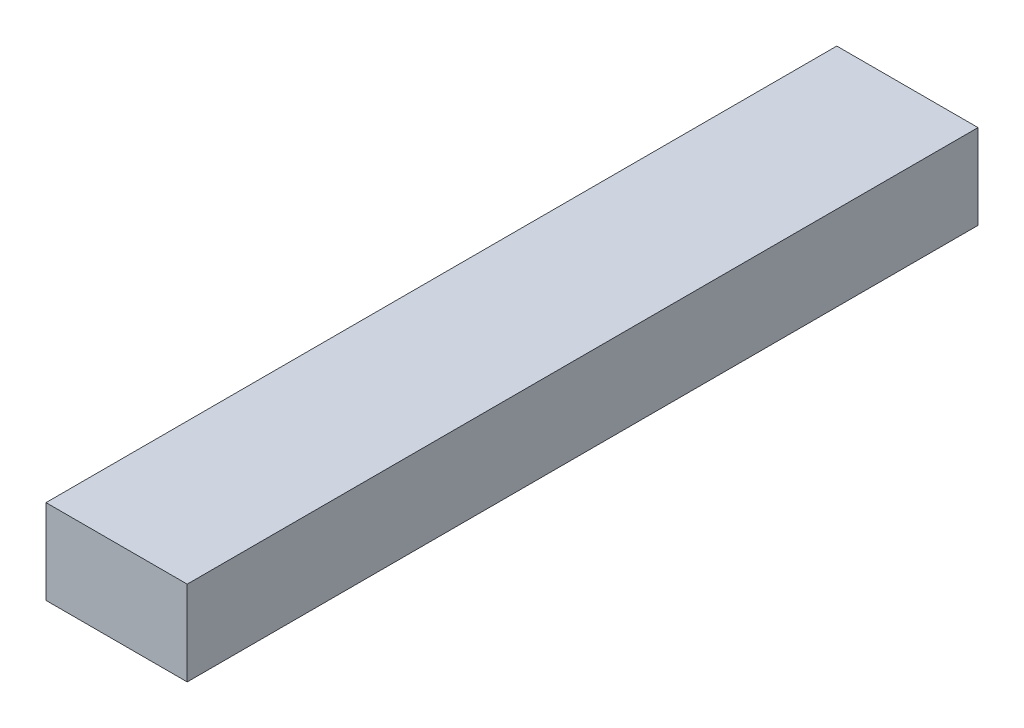
from build123d import *

# Parameters (mm, degrees)
SKETCH1_W           = 7.9375
SKETCH1_H           = 44.45
BOSS_EXTRUDE1_DEPTH = 4.7625


with BuildPart() as part:
    # Sketch1 → Boss-Extrude1 (new body)
    with BuildSketch(Plane(origin=(0, 0, 0), x_dir=(1, 0, 0), z_dir=(0, 1, 0))):
        with Locations((3.96875, 22.225)):
            Rectangle(SKETCH1_W, SKETCH1_H)
    extrude(amount=BOSS_EXTRUDE1_DEPTH)


solid = part.part
